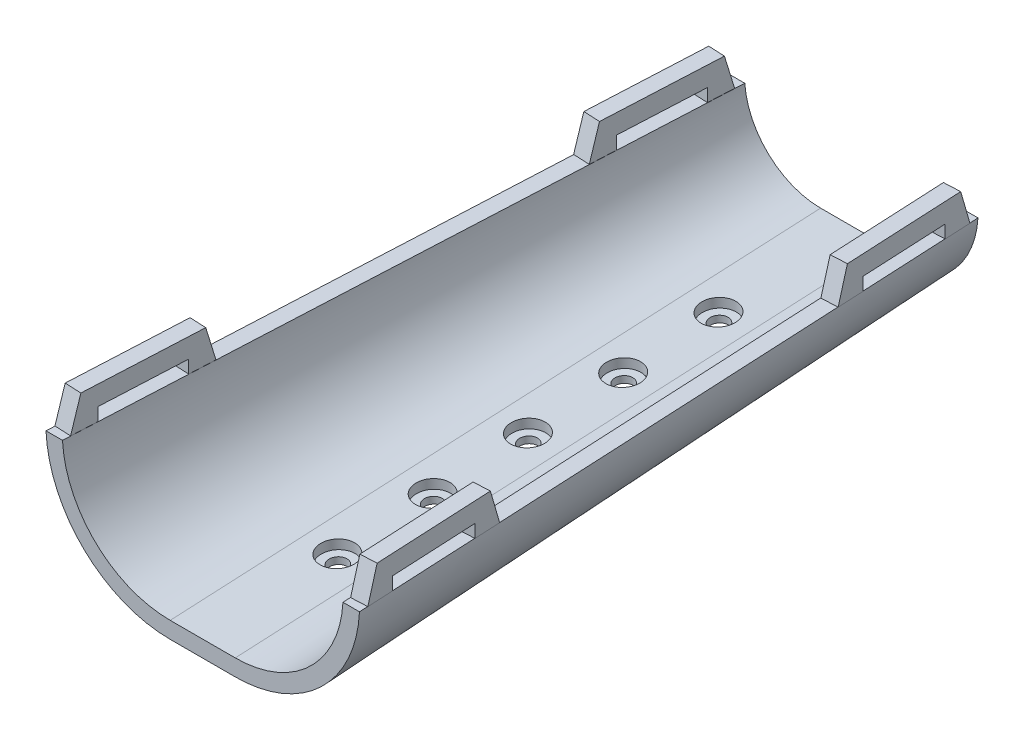
from build123d import *

# Parameters (mm, degrees)
BOSS_EXTRUDE1_DEPTH                       = 150
BOSS_EXTRUDE1_DRAFT                       = -2.8
CUT_EXTRUDE1_DEPTH                        = 157.704023919
CUT_EXTRUDE1_DRAFT                        = -2.8
SKETCH4_W                                 = 86.570961738
SKETCH4_H                                 = 17.749989686
CUT_EXTRUDE2_DEPTH                        = 157.704023919
BOSS_EXTRUDE2_DEPTH                       = 3.8
BOSS_EXTRUDE3_DEPTH                       = 3.8
CBORE_FOR_M4_SBHCS1_D                     = 4.2
CBORE_FOR_M4_SBHCS1_CBORE_D               = 8
CBORE_FOR_M4_SBHCS1_CBORE_DEPTH           = 2.2
CBORE_FOR_M4_SBHCS1_ON_FACE_2_D           = 4.2
CBORE_FOR_M4_SBHCS1_ON_FACE_2_CBORE_D     = 8
CBORE_FOR_M4_SBHCS1_ON_FACE_2_CBORE_DEPTH = 2.2
CBORE_FOR_M4_SBHCS1_ON_FACE_3_D           = 4.2
CBORE_FOR_M4_SBHCS1_ON_FACE_3_CBORE_D     = 8
CBORE_FOR_M4_SBHCS1_ON_FACE_3_CBORE_DEPTH = 2.2
CBORE_FOR_M4_SBHCS1_ON_FACE_4_D           = 4.2
CBORE_FOR_M4_SBHCS1_ON_FACE_4_CBORE_D     = 8
CBORE_FOR_M4_SBHCS1_ON_FACE_4_CBORE_DEPTH = 2.2
CBORE_FOR_M4_SBHCS1_ON_FACE_5_D           = 4.2
CBORE_FOR_M4_SBHCS1_ON_FACE_5_CBORE_D     = 8
CBORE_FOR_M4_SBHCS1_ON_FACE_5_CBORE_DEPTH = 2.2


with BuildPart() as part:
    # Sketch1 → Boss-Extrude1 (with draft: the straight prism first)
    with BuildSketch(Plane.XY):
        with BuildLine():
            ThreePointArc((-28.8, 20), (-22.10898696, 5.783678888), (-7.5, 0))
            Line((-7.5, 0), (7.5, 0))
            ThreePointArc((7.5, 0), (22.10898696, 5.783678888), (28.8, 20))
            Line((28.8, 20), (-28.8, 20))
        make_face()
    extrude(amount=BOSS_EXTRUDE1_DEPTH)
    # Boss-Extrude1: the draft: its side faces are tilted about the plane it starts from
    boss_extrude1_sides = [part.faces().sort_by_distance(p)[0] for p in [
        (22.10898696, 5.783678888, 75),
        (0, 20, 75),
        (-22.10898696, 5.783678888, 75),
        (0, 0, 75),
    ]]
    draft(boss_extrude1_sides, Plane.XY, BOSS_EXTRUDE1_DRAFT)


with BuildPart() as cut_extrude1_tool:
    # Sketch1_3 → Cut-Extrude1 (with draft: the straight prism first)
    with BuildSketch(Plane.XY):
        with BuildLine():
            Line((24.990823308, 20), (-24.990823308, 20))
            ThreePointArc((-24.990823308, 20), (-19.420244335, 8.472195219), (-7.5, 3.8))
            Line((-7.5, 3.8), (7.5, 3.8))
            ThreePointArc((7.5, 3.8), (19.420244335, 8.472195219), (24.990823308, 20))
        make_face()
    extrude(amount=CUT_EXTRUDE1_DEPTH)
    # Cut-Extrude1: the draft: its side faces are tilted about the plane it starts from
    cut_extrude1_sides = [cut_extrude1_tool.faces().sort_by_distance(p)[0] for p in [
        (0, 3.8, 78.85201196),
        (19.420244335, 8.472195219, 78.85201196),
        (0, 20, 78.85201196),
        (-19.420244335, 8.472195219, 78.85201196),
    ]]
    draft(cut_extrude1_sides, Plane.XY, CUT_EXTRUDE1_DRAFT)


with BuildPart() as part_1:
    add(part.part)

    # Cut-Extrude1: cut by cut_extrude1_tool
    add(cut_extrude1_tool.part, mode=Mode.SUBTRACT)

    # Sketch4 → Cut-Extrude2 (cut, through all)
    with BuildSketch(Plane(origin=(0, 0, 0), x_dir=(-1, 0, 0), z_dir=(0, 0, -1))):
        with Locations((0, 28.874994843)):
            Rectangle(SKETCH4_W, SKETCH4_H)
    extrude(amount=-CUT_EXTRUDE2_DEPTH, mode=Mode.SUBTRACT)

    # Sketch5 → Boss-Extrude2 (add)
    with BuildSketch(Plane(origin=(28.773423739, 0, -1.407255195), x_dir=(-0.04884976979561336, 0, -0.9988061373414341), z_dir=(0.9988061373414341, 0, -0.04884976979561336))):
        Polygon((-149.586695466, 20), (-147.336695466, 27.5), (-119.836695466, 27.5), (-117.586695466, 20), (-123.586695466, 20), (-123.586695466, 23), (-143.586695466, 23), (-143.586695466, 20), align=None)
        Polygon((-9.40687337, 23), (-9.40687337, 20), (-3.40687337, 20), (-5.65687337, 27.5), (-33.15687337, 27.5), (-35.40687337, 20), (-29.40687337, 20), (-29.40687337, 23), align=None)
    extrude(amount=-BOSS_EXTRUDE2_DEPTH)

    # Sketch6 → Boss-Extrude3 (add)
    with BuildSketch(Plane(origin=(-28.773423739, 0, -1.407255195), x_dir=(-0.04884976979561336, 0, 0.9988061373414341), z_dir=(-0.9988061373414341, 0, -0.04884976979561336))):
        Polygon((149.586695466, 20), (147.336695466, 27.5), (119.836695466, 27.5), (117.586695466, 20), (123.586695466, 20), (123.586695466, 23), (143.586695466, 23), (143.586695466, 20), align=None)
        Polygon((9.40687337, 23), (9.40687337, 20), (3.40687337, 20), (5.65687337, 27.5), (33.15687337, 27.5), (35.40687337, 20), (29.40687337, 20), (29.40687337, 23), align=None)
    extrude(amount=-BOSS_EXTRUDE3_DEPTH)

    # CBORE for M4 SBHCS1 (through all)
    with Locations(Plane(origin=(0, -2.017501828, 118.947470043), x_dir=(0, -0.048849769796, 0.998806137341), z_dir=(0, 0.998806137341, 0.048849769796))):
        with Locations((0, 0)):
            CounterBoreHole(CBORE_FOR_M4_SBHCS1_D / 2, CBORE_FOR_M4_SBHCS1_CBORE_D / 2, CBORE_FOR_M4_SBHCS1_CBORE_DEPTH)

    # CBORE for M4 SBHCS1 on face 2 (through all)
    with Locations(Plane(origin=(0, -0.942806892, 96.973735022), x_dir=(0, -0.048850006152, 0.998806125782), z_dir=(0, 0.998806125782, 0.048850006152))):
        with Locations((0, 0)):
            CounterBoreHole(CBORE_FOR_M4_SBHCS1_ON_FACE_2_D / 2, CBORE_FOR_M4_SBHCS1_ON_FACE_2_CBORE_D / 2, CBORE_FOR_M4_SBHCS1_ON_FACE_2_CBORE_DEPTH)

    # CBORE for M4 SBHCS1 on face 3 (through all)
    with Locations(Plane(origin=(0, 0.131888043, 75), x_dir=(0, -0.048850006152, 0.998806125782), z_dir=(0, 0.998806125782, 0.048850006152))):
        with Locations((0, 0)):
            CounterBoreHole(CBORE_FOR_M4_SBHCS1_ON_FACE_3_D / 2, CBORE_FOR_M4_SBHCS1_ON_FACE_3_CBORE_D / 2, CBORE_FOR_M4_SBHCS1_ON_FACE_3_CBORE_DEPTH)

    # CBORE for M4 SBHCS1 on face 4 (through all)
    with Locations(Plane(origin=(0, 1.206582979, 53.026264978), x_dir=(0, -0.048850006152, 0.998806125782), z_dir=(0, 0.998806125782, 0.048850006152))):
        with Locations((0, 0)):
            CounterBoreHole(CBORE_FOR_M4_SBHCS1_ON_FACE_4_D / 2, CBORE_FOR_M4_SBHCS1_ON_FACE_4_CBORE_D / 2, CBORE_FOR_M4_SBHCS1_ON_FACE_4_CBORE_DEPTH)

    # CBORE for M4 SBHCS1 on face 5 (through all)
    with Locations(Plane(origin=(0, 2.281277914, 31.052529957), x_dir=(0, -0.048850006152, 0.998806125782), z_dir=(0, 0.998806125782, 0.048850006152))):
        with Locations((0, 0)):
            CounterBoreHole(CBORE_FOR_M4_SBHCS1_ON_FACE_5_D / 2, CBORE_FOR_M4_SBHCS1_ON_FACE_5_CBORE_D / 2, CBORE_FOR_M4_SBHCS1_ON_FACE_5_CBORE_DEPTH)


solid = part_1.part
